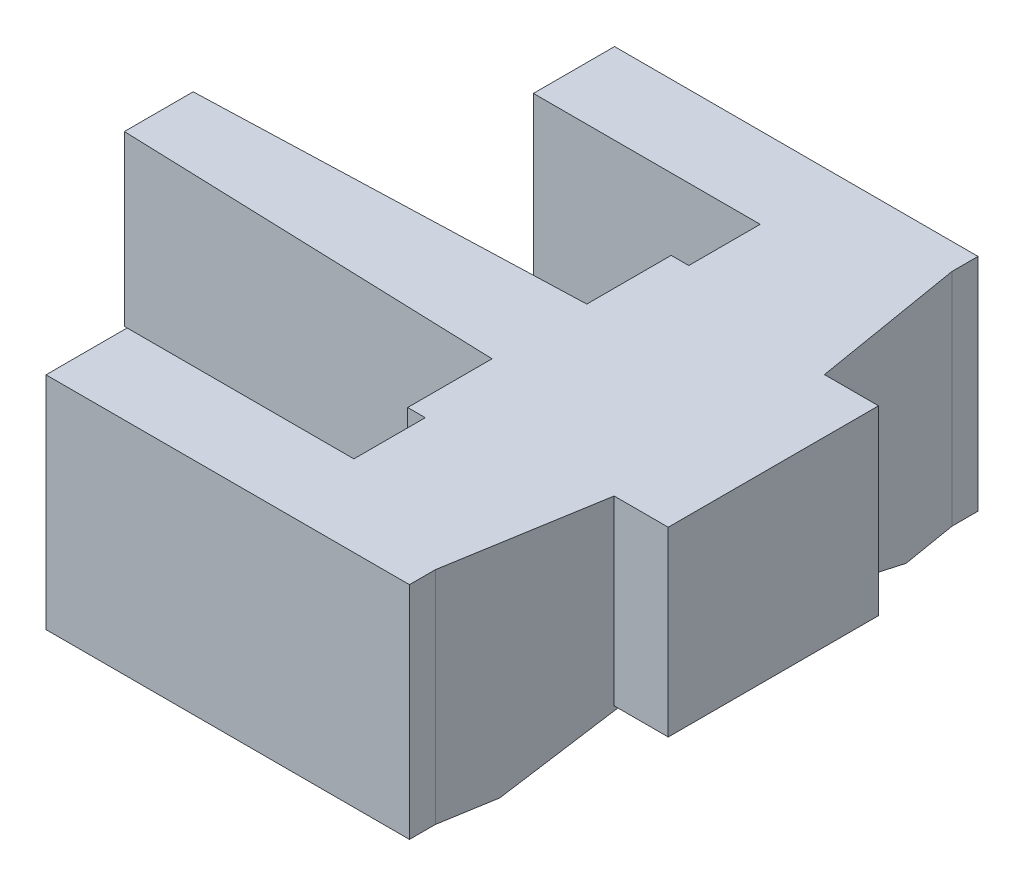
from build123d import *

# Parameters (mm, degrees)
BOSS_EXTRUDE1_DEPTH     = 17
SKETCH2_R               = 2.5
BOSS_EXTRUDE2_DEPTH     = 1
CUT_EXTRUDE1_DEPTH      = 3
CUT_EXTRUDE5_DEPTH      = 2
CUT_EXTRUDE5_DEPTH_BACK = 3
SKETCH5_W               = 1.356176493
SKETCH5_H               = 3
CUT_EXTRUDE6_DEPTH      = 3
CUT_EXTRUDE11_DEPTH     = 20
CUT_EXTRUDE12_DEPTH     = 1
SKETCH12_W              = 28
SKETCH12_H              = 17
BOSS_EXTRUDE3_DEPTH     = 2
SKETCH13_W              = 28
SKETCH13_H              = 17
BOSS_EXTRUDE4_DEPTH     = 2
SKETCH14_W              = 1.356176493
SKETCH14_H              = 14
BOSS_EXTRUDE5_DEPTH     = 1
SKETCH15_W              = 1.356176493
SKETCH15_H              = 14
BOSS_EXTRUDE6_DEPTH     = 1
BOSS_EXTRUDE7_DEPTH     = 1
BOSS_EXTRUDE8_DEPTH     = 1
SKETCH18_W              = 1.356176493
SKETCH18_H              = 14
BOSS_EXTRUDE9_DEPTH     = 2
SKETCH19_W              = 1.356176493
SKETCH19_H              = 14
BOSS_EXTRUDE10_DEPTH    = 2


with BuildPart() as part:
    # Sketch1 → Boss-Extrude1 (new body)
    with BuildSketch(Plane(origin=(0, 0, 0), x_dir=(1, 0, 0), z_dir=(0, 1, 0))):
        Polygon((53.231444905, 93.562909441), (55.368661466, 80.762909441), (59.368661466, 80.762909441), (59.368661466, 66.562909441), (55.368661466, 66.562909441), (53.231444905, 53.762909441), (25.231444905, 53.762909441), (25.231444905, 58.012909441), (42.701133317, 58.012909441), (42.701133317, 66.512909441), (41.344956824, 66.512909441), (41.344956824, 70.012909441), (12.018661466, 71.012909441), (12.018661466, 76.312909441), (41.344956824, 77.312909441), (41.344956824, 80.812909441), (42.701133317, 80.812909441), (42.701133317, 89.312909441), (25.231444905, 89.312909441), (25.231444905, 93.562909441), align=None)
    extrude(amount=BOSS_EXTRUDE1_DEPTH)

    # Sketch2 → Boss-Extrude2 (add)
    with BuildSketch(Plane.XZ):
        with Locations((42.701133317, -73.662909441)):
            Circle(SKETCH2_R)
    extrude(amount=BOSS_EXTRUDE2_DEPTH)

    # Sketch3 → Cut-Extrude1 (cut)
    with BuildSketch(Plane(origin=(0, 0, 0), x_dir=(-1, 0, 0), z_dir=(0, -1, 0))):
        with BuildLine():
            Line((-42.701133317, 80.812909441), (-55.368661466, 80.762909441))
            Line((-55.368661466, 80.762909441), (-59.368661466, 80.762909441))
            Line((-59.368661466, 80.762909441), (-59.368661466, 66.562909441))
            Line((-59.368661466, 66.562909441), (-41.344956824, 66.512909441))
            Line((-41.344956824, 66.512909441), (-41.344956824, 70.012909441))
            Line((-41.344956824, 70.012909441), (-41.344956824, 71.562722468))
            ThreePointArc((-41.344956824, 71.562722468), (-45.201133317, 73.662909441), (-41.344956824, 75.763096414))
            Line((-41.344956824, 75.763096414), (-41.344956824, 77.312909441))
            Line((-41.344956824, 77.312909441), (-41.344956824, 80.812909441))
            Line((-41.344956824, 80.812909441), (-42.701133317, 80.812909441))
        make_face()
    extrude(amount=-CUT_EXTRUDE1_DEPTH, mode=Mode.SUBTRACT)

    # Sketch4 → Cut-Extrude5 (cut, two sides)
    with BuildSketch(Plane.XZ) as cut_extrude5_sk:
        with BuildLine():
            Line((12.018661466, -76.312909441), (41.344956824, -77.312909441))
            Line((41.344956824, -77.312909441), (41.344956824, -77.220900459))
            Line((41.344956824, -77.220900459), (41.344956824, -75.763096414))
            ThreePointArc((41.344956824, -75.763096414), (40.201133317, -73.662909441), (41.344956824, -71.562722468))
            Line((41.344956824, -71.562722468), (41.344956824, -70.012909441))
            Line((41.344956824, -70.012909441), (12.018661466, -71.012909441))
            Line((12.018661466, -71.012909441), (12.018661466, -76.312909441))
        make_face()
    extrude(amount=CUT_EXTRUDE5_DEPTH, mode=Mode.SUBTRACT)
    extrude(cut_extrude5_sk.sketch, amount=-CUT_EXTRUDE5_DEPTH_BACK, mode=Mode.SUBTRACT)

    # Sketch5 → Cut-Extrude6 (cut)
    with BuildSketch(Plane.XY.offset(-66.512909441)):
        with Locations((42.023045071, 1.5)):
            Rectangle(SKETCH5_W, SKETCH5_H)
    extrude(amount=-CUT_EXTRUDE6_DEPTH, mode=Mode.SUBTRACT)

    # Sketch7 → Cut-Extrude11 (cut)
    with BuildSketch(Plane.ZY.offset(-42.701133317)):
        Polygon((-66.516671643, 0), (-67.290586566, 0), (-67.290586566, 3), (-66.512909441, 3), (-58.012909441, 0), align=None)
        Polygon((-89.312909441, 0), (-80.812909441, 0), (-79.713237651, 0), (-79.713237651, 3), (-80.812909441, 3), align=None)
    extrude(amount=-CUT_EXTRUDE11_DEPTH, mode=Mode.SUBTRACT)

    # Sketch11 → Cut-Extrude12 (cut)
    with BuildSketch(Plane.XZ.offset(-3)):
        with BuildLine():
            Line((41.344956824, -77.312909441), (41.344956824, -75.763096414))
            ThreePointArc((41.344956824, -75.763096414), (40.201133317, -73.662909441), (41.344956824, -71.562722468))
            Line((41.344956824, -71.562722468), (41.344956824, -70.012909441))
            Line((41.344956824, -70.012909441), (12.018661466, -71.012909441))
            Line((12.018661466, -71.012909441), (12.018661466, -76.312909441))
            Line((12.018661466, -76.312909441), (41.344956824, -77.312909441))
        make_face()
    extrude(amount=-CUT_EXTRUDE12_DEPTH, mode=Mode.SUBTRACT)

    # Sketch12 → Boss-Extrude3 (add)
    with BuildSketch(Plane(origin=(0, 0, -93.562909441), x_dir=(-1, 0, 0), z_dir=(0, 0, -1))):
        with Locations((-39.231444905, 8.5)):
            Rectangle(SKETCH12_W, SKETCH12_H)
    extrude(amount=BOSS_EXTRUDE3_DEPTH)

    # Sketch13 → Boss-Extrude4 (add)
    with BuildSketch(Plane.XY.offset(-53.762909441)):
        with Locations((39.231444905, 8.5)):
            Rectangle(SKETCH13_W, SKETCH13_H)
    extrude(amount=BOSS_EXTRUDE4_DEPTH)

    # Sketch14 → Boss-Extrude5 (add)
    with BuildSketch(Plane.XY.offset(-66.512909441)):
        with Locations((42.023045071, 10)):
            Rectangle(SKETCH14_W, SKETCH14_H)
    extrude(amount=BOSS_EXTRUDE5_DEPTH)

    # Sketch15 → Boss-Extrude6 (add)
    with BuildSketch(Plane(origin=(0, 0, -80.812909441), x_dir=(-1, 0, 0), z_dir=(0, 0, -1))):
        with Locations((-42.023045071, 10)):
            Rectangle(SKETCH15_W, SKETCH15_H)
    extrude(amount=BOSS_EXTRUDE6_DEPTH)

    # Sketch16 → Boss-Extrude7 (add)
    with BuildSketch(Plane.XY.offset(-66.562909441)):
        Polygon((59.368661466, 3), (55.368661466, 3), (53.667179365, 3), (53.667179365, 17), (55.368661466, 17), (59.368661466, 17), align=None)
    extrude(amount=BOSS_EXTRUDE7_DEPTH)

    # Sketch17 → Boss-Extrude8 (add)
    with BuildSketch(Plane(origin=(0, 0, -80.762909441), x_dir=(-1, 0, 0), z_dir=(0, 0, -1))):
        Polygon((-59.368661466, 3), (-55.368661466, 3), (-53.078047716, 3), (-53.078047716, 17), (-55.368661466, 17), (-59.368661466, 17), align=None)
    extrude(amount=BOSS_EXTRUDE8_DEPTH)

    # Sketch18 → Boss-Extrude9 (add)
    with BuildSketch(Plane.XY.offset(-65.512909441)):
        with Locations((42.023045071, 10)):
            Rectangle(SKETCH18_W, SKETCH18_H)
    extrude(amount=BOSS_EXTRUDE9_DEPTH)

    # Sketch19 → Boss-Extrude10 (add)
    with BuildSketch(Plane(origin=(0, 0, -81.812909441), x_dir=(-1, 0, 0), z_dir=(0, 0, -1))):
        with Locations((-42.023045071, 10)):
            Rectangle(SKETCH19_W, SKETCH19_H)
    extrude(amount=BOSS_EXTRUDE10_DEPTH)


solid = part.part
